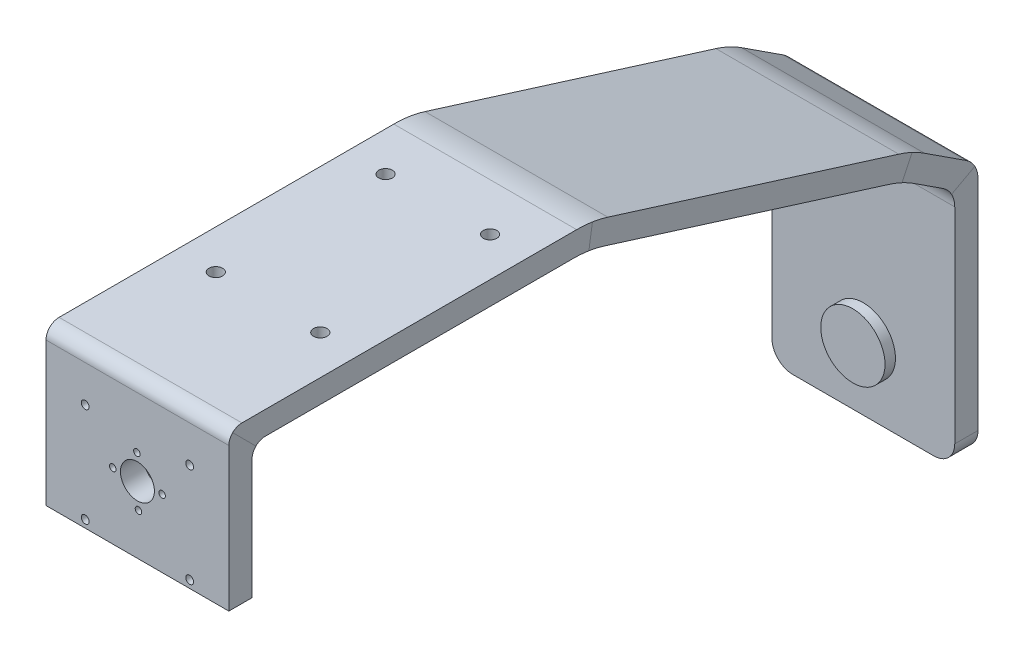
from build123d import *

# Parameters (mm, degrees)
SKETCH3_W           = 70
SKETCH3_H           = 8.9
SKETCH4_R           = 12.3
BOSS_EXTRUDE1_DEPTH = 4
FILLET1_R           = 10
FILLET2_R           = 40
FILLET3_R           = 8
FILLET4_R           = 40
FILLET5_R           = 5
CUT_EXTRUDE1_REACH  = 288.8
SKETCH5_R           = 6.5
SKETCH5_R_2         = 1.25
CUT_EXTRUDE2_REACH  = 153.4
SKETCH6_R           = 2.6
CUT_EXTRUDE3_REACH  = 288.8
SKETCH7_R           = 1.5


with BuildPart() as part:
    # Sweep1: sweep along a path in Sketch1
    with BuildLine(Plane(origin=(0, 0, 0), x_dir=(0, 0, -1), z_dir=(1, 0, 0))) as sweep1_path:
        Line((-269, 61.5), (-269, 112.5))
        Line((-269, 112.5), (-140, 112.5))
        Line((-140, 112.5), (-20, 75))
        Line((-20, 75), (0, 62))
        Line((0, 62), (0, 0))
        Line((0, 0), (0, -30))
    # Sketch3 → Sweep1 (sweep)
    with BuildSketch(Plane(origin=(0, 0, 0), x_dir=(1, 0, 0), z_dir=(0, 1, 0))):
        with Locations((0, 4.45)):
            Rectangle(SKETCH3_W, SKETCH3_H)
    sweep(path=sweep1_path.line, transition=Transition.RIGHT)

    # Sketch4 → Boss-Extrude1 (add)
    with BuildSketch(Plane.XY):
        with Locations((0, -5)):
            Circle(SKETCH4_R)
    extrude(amount=BOSS_EXTRUDE1_DEPTH)

    # Fillet1
    fillet1_edges = [part.edges().sort_by_distance(p)[0] for p in [
        (0, 66.829905793, -8.9),
        (0, 62, 0),
    ]]
    fillet(fillet1_edges, radius=FILLET1_R)

    # Fillet2
    fillet2_edges = [part.edges().sort_by_distance(p)[0] for p in [
        (0, 83.129581848, 16.176424699),
        (0, 75, 20),
    ]]
    fillet(fillet2_edges, radius=FILLET2_R)

    # Fillet3
    fillet3_edges = [part.edges().sort_by_distance(p)[0] for p in [
        (35, -30, -4.45),
        (-35, -30, -4.45),
    ]]
    fillet(fillet3_edges, radius=FILLET3_R)

    # Fillet4
    fillet4_edges = [part.edges().sort_by_distance(p)[0] for p in [
        (0, 121.4, 138.641762787),
        (0, 112.5, 140),
    ]]
    fillet(fillet4_edges, radius=FILLET4_R)

    # Fillet5
    fillet5_edges = [part.edges().sort_by_distance(p)[0] for p in [
        (0, 112.5, 269),
        (0, 121.4, 277.9),
    ]]
    fillet(fillet5_edges, radius=FILLET5_R)

    # Sketch5 → Cut-Extrude1 (cut, up to next)
    with BuildSketch(Plane.XY.offset(277.9), mode=Mode.PRIVATE) as cut_extrude1_sk1:
        with Locations((0, 87.04)):
            Circle(SKETCH5_R)
    cut_extrude1_tool1 = extrude(cut_extrude1_sk1.sketch, amount=-CUT_EXTRUDE1_REACH, mode=Mode.PRIVATE) & part.part
    add(cut_extrude1_tool1.solids().sort_by_distance((0, 87.04, 277.9))[0], mode=Mode.SUBTRACT)
    # Sketch5 → Cut-Extrude1 (cut, up to next)
    with BuildSketch(Plane.XY.offset(277.9), mode=Mode.PRIVATE) as cut_extrude1_sk2:
        with Locations((-0.2, 96.49)):
            Circle(SKETCH5_R_2)
    cut_extrude1_tool2 = extrude(cut_extrude1_sk2.sketch, amount=-CUT_EXTRUDE1_REACH, mode=Mode.PRIVATE) & part.part
    add(cut_extrude1_tool2.solids().sort_by_distance((-0.2, 96.49, 277.9))[0], mode=Mode.SUBTRACT)
    # Sketch5 → Cut-Extrude1 (cut, up to next)
    with BuildSketch(Plane.XY.offset(277.9), mode=Mode.PRIVATE) as cut_extrude1_sk3:
        with Locations((0.4, 77.59)):
            Circle(SKETCH5_R_2)
    cut_extrude1_tool3 = extrude(cut_extrude1_sk3.sketch, amount=-CUT_EXTRUDE1_REACH, mode=Mode.PRIVATE) & part.part
    add(cut_extrude1_tool3.solids().sort_by_distance((0.4, 77.59, 277.9))[0], mode=Mode.SUBTRACT)
    # Sketch5 → Cut-Extrude1 (cut, up to next)
    with BuildSketch(Plane.XY.offset(277.9), mode=Mode.PRIVATE) as cut_extrude1_sk4:
        with Locations((-9.45, 86.84)):
            Circle(SKETCH5_R_2)
    cut_extrude1_tool4 = extrude(cut_extrude1_sk4.sketch, amount=-CUT_EXTRUDE1_REACH, mode=Mode.PRIVATE) & part.part
    add(cut_extrude1_tool4.solids().sort_by_distance((-9.45, 86.84, 277.9))[0], mode=Mode.SUBTRACT)
    # Sketch5 → Cut-Extrude1 (cut, up to next)
    with BuildSketch(Plane.XY.offset(277.9), mode=Mode.PRIVATE) as cut_extrude1_sk5:
        with Locations((9.45, 87.44)):
            Circle(SKETCH5_R_2)
    cut_extrude1_tool5 = extrude(cut_extrude1_sk5.sketch, amount=-CUT_EXTRUDE1_REACH, mode=Mode.PRIVATE) & part.part
    add(cut_extrude1_tool5.solids().sort_by_distance((9.45, 87.44, 277.9))[0], mode=Mode.SUBTRACT)

    # Sketch6 → Cut-Extrude2 (cut, up to next)
    with BuildSketch(Plane(origin=(0, 121.4, 0), x_dir=(1, 0, 0), z_dir=(0, 1, 0)), mode=Mode.PRIVATE) as cut_extrude2_sk1:
        with Locations((-20, -162.9)):
            Circle(SKETCH6_R)
    cut_extrude2_tool1 = extrude(cut_extrude2_sk1.sketch, amount=-CUT_EXTRUDE2_REACH, mode=Mode.PRIVATE) & part.part
    add(cut_extrude2_tool1.solids().sort_by_distance((-20, 121.4, 162.9))[0], mode=Mode.SUBTRACT)
    # Sketch6 → Cut-Extrude2 (cut, up to next)
    with BuildSketch(Plane(origin=(0, 121.4, 0), x_dir=(1, 0, 0), z_dir=(0, 1, 0)), mode=Mode.PRIVATE) as cut_extrude2_sk2:
        with Locations((20, -162.9)):
            Circle(SKETCH6_R)
    cut_extrude2_tool2 = extrude(cut_extrude2_sk2.sketch, amount=-CUT_EXTRUDE2_REACH, mode=Mode.PRIVATE) & part.part
    add(cut_extrude2_tool2.solids().sort_by_distance((20, 121.4, 162.9))[0], mode=Mode.SUBTRACT)
    # Sketch6 → Cut-Extrude2 (cut, up to next)
    with BuildSketch(Plane(origin=(0, 121.4, 0), x_dir=(1, 0, 0), z_dir=(0, 1, 0)), mode=Mode.PRIVATE) as cut_extrude2_sk3:
        with Locations((-20, -227.9)):
            Circle(SKETCH6_R)
    cut_extrude2_tool3 = extrude(cut_extrude2_sk3.sketch, amount=-CUT_EXTRUDE2_REACH, mode=Mode.PRIVATE) & part.part
    add(cut_extrude2_tool3.solids().sort_by_distance((-20, 121.4, 227.9))[0], mode=Mode.SUBTRACT)
    # Sketch6 → Cut-Extrude2 (cut, up to next)
    with BuildSketch(Plane(origin=(0, 121.4, 0), x_dir=(1, 0, 0), z_dir=(0, 1, 0)), mode=Mode.PRIVATE) as cut_extrude2_sk4:
        with Locations((20, -227.9)):
            Circle(SKETCH6_R)
    cut_extrude2_tool4 = extrude(cut_extrude2_sk4.sketch, amount=-CUT_EXTRUDE2_REACH, mode=Mode.PRIVATE) & part.part
    add(cut_extrude2_tool4.solids().sort_by_distance((20, 121.4, 227.9))[0], mode=Mode.SUBTRACT)

    # Sketch7 → Cut-Extrude3 (cut, up to next)
    with BuildSketch(Plane.XY.offset(277.9), mode=Mode.PRIVATE) as cut_extrude3_sk1:
        with Locations((20, 102.4)):
            Circle(SKETCH7_R)
    cut_extrude3_tool1 = extrude(cut_extrude3_sk1.sketch, amount=-CUT_EXTRUDE3_REACH, mode=Mode.PRIVATE) & part.part
    add(cut_extrude3_tool1.solids().sort_by_distance((20, 102.4, 277.9))[0], mode=Mode.SUBTRACT)
    # Sketch7 → Cut-Extrude3 (cut, up to next)
    with BuildSketch(Plane.XY.offset(277.9), mode=Mode.PRIVATE) as cut_extrude3_sk2:
        with Locations((20, 64.4)):
            Circle(SKETCH7_R)
    cut_extrude3_tool2 = extrude(cut_extrude3_sk2.sketch, amount=-CUT_EXTRUDE3_REACH, mode=Mode.PRIVATE) & part.part
    add(cut_extrude3_tool2.solids().sort_by_distance((20, 64.4, 277.9))[0], mode=Mode.SUBTRACT)
    # Sketch7 → Cut-Extrude3 (cut, up to next)
    with BuildSketch(Plane.XY.offset(277.9), mode=Mode.PRIVATE) as cut_extrude3_sk3:
        with Locations((-20, 102.4)):
            Circle(SKETCH7_R)
    cut_extrude3_tool3 = extrude(cut_extrude3_sk3.sketch, amount=-CUT_EXTRUDE3_REACH, mode=Mode.PRIVATE) & part.part
    add(cut_extrude3_tool3.solids().sort_by_distance((-20, 102.4, 277.9))[0], mode=Mode.SUBTRACT)
    # Sketch7 → Cut-Extrude3 (cut, up to next)
    with BuildSketch(Plane.XY.offset(277.9), mode=Mode.PRIVATE) as cut_extrude3_sk4:
        with Locations((-20, 64.4)):
            Circle(SKETCH7_R)
    cut_extrude3_tool4 = extrude(cut_extrude3_sk4.sketch, amount=-CUT_EXTRUDE3_REACH, mode=Mode.PRIVATE) & part.part
    add(cut_extrude3_tool4.solids().sort_by_distance((-20, 64.4, 277.9))[0], mode=Mode.SUBTRACT)


solid = part.part
